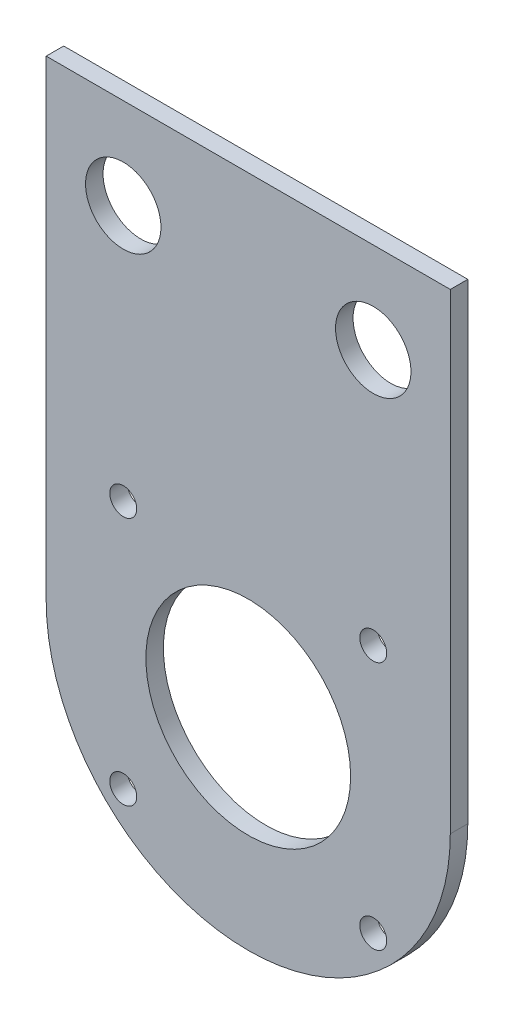
from build123d import *

# Parameters (mm, degrees)
SKETCH1_R           = 7.112
SKETCH1_R_2         = 2.54
SKETCH1_R_3         = 19.304
BOSS_EXTRUDE1_DEPTH = 3.302


with BuildPart() as part:
    # Sketch1 → Boss-Extrude1 (new body)
    with BuildSketch(Plane.XY):
        with BuildLine():
            Line((-38.1, 0), (-38.1, 88.9))
            Line((-38.1, 88.9), (38.1, 88.9))
            Line((38.1, 88.9), (38.1, 0))
            ThreePointArc((38.1, 0), (0, -38.1), (-38.1, 0))
        make_face()
        with Locations((23.57, 71.755)):
            Circle(SKETCH1_R, mode=Mode.SUBTRACT)
        with Locations((23.57, 23.495)):
            Circle(SKETCH1_R_2, mode=Mode.SUBTRACT)
        with Locations((-23.57, -23.495)):
            Circle(SKETCH1_R_2, mode=Mode.SUBTRACT)
        with Locations((-23.57, 23.495)):
            Circle(SKETCH1_R_2, mode=Mode.SUBTRACT)
        with Locations((-23.57, 71.755)):
            Circle(SKETCH1_R, mode=Mode.SUBTRACT)
        with Locations((23.57, -23.495)):
            Circle(SKETCH1_R_2, mode=Mode.SUBTRACT)
        Circle(SKETCH1_R_3, mode=Mode.SUBTRACT)
    extrude(amount=BOSS_EXTRUDE1_DEPTH)


solid = part.part
